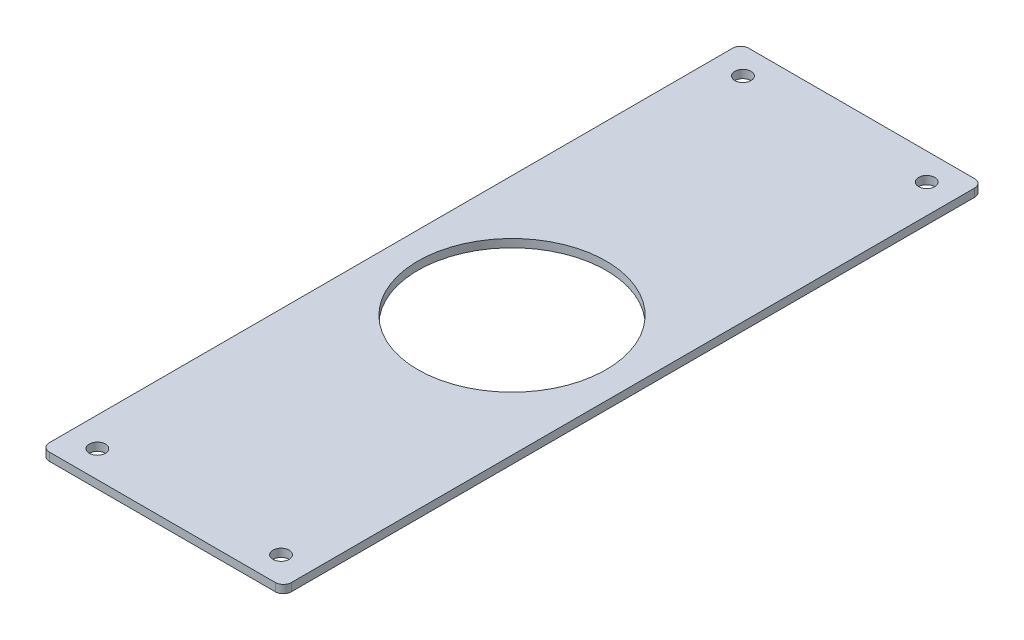
from build123d import *

# Parameters (mm, degrees)
SKETCH1_W           = 90
SKETCH1_H           = 260
SKETCH1_R           = 35
SKETCH1_R_2         = 3
BOSS_EXTRUDE1_DEPTH = 3
FILLET1_R           = 3


with BuildPart() as part:
    # Sketch1 → Boss-Extrude1 (new body)
    with BuildSketch(Plane(origin=(0, 0, 0), x_dir=(1, 0, 0), z_dir=(0, 1, 0))):
        Rectangle(SKETCH1_W, SKETCH1_H)
        Circle(SKETCH1_R, mode=Mode.SUBTRACT)
        with Locations((-34.15, 120)):
            Circle(SKETCH1_R_2, mode=Mode.SUBTRACT)
        with Locations((34.15, 120)):
            Circle(SKETCH1_R_2, mode=Mode.SUBTRACT)
        with Locations((34.15, -120)):
            Circle(SKETCH1_R_2, mode=Mode.SUBTRACT)
        with Locations((-34.15, -120)):
            Circle(SKETCH1_R_2, mode=Mode.SUBTRACT)
    extrude(amount=BOSS_EXTRUDE1_DEPTH)

    # Fillet1
    fillet1_edges = [part.edges().sort_by_distance(p)[0] for p in [
        (45, 1.5, 130),
        (-45, 1.5, 130),
        (-45, 1.5, -130),
        (45, 1.5, -130),
    ]]
    fillet(fillet1_edges, radius=FILLET1_R)


solid = part.part
